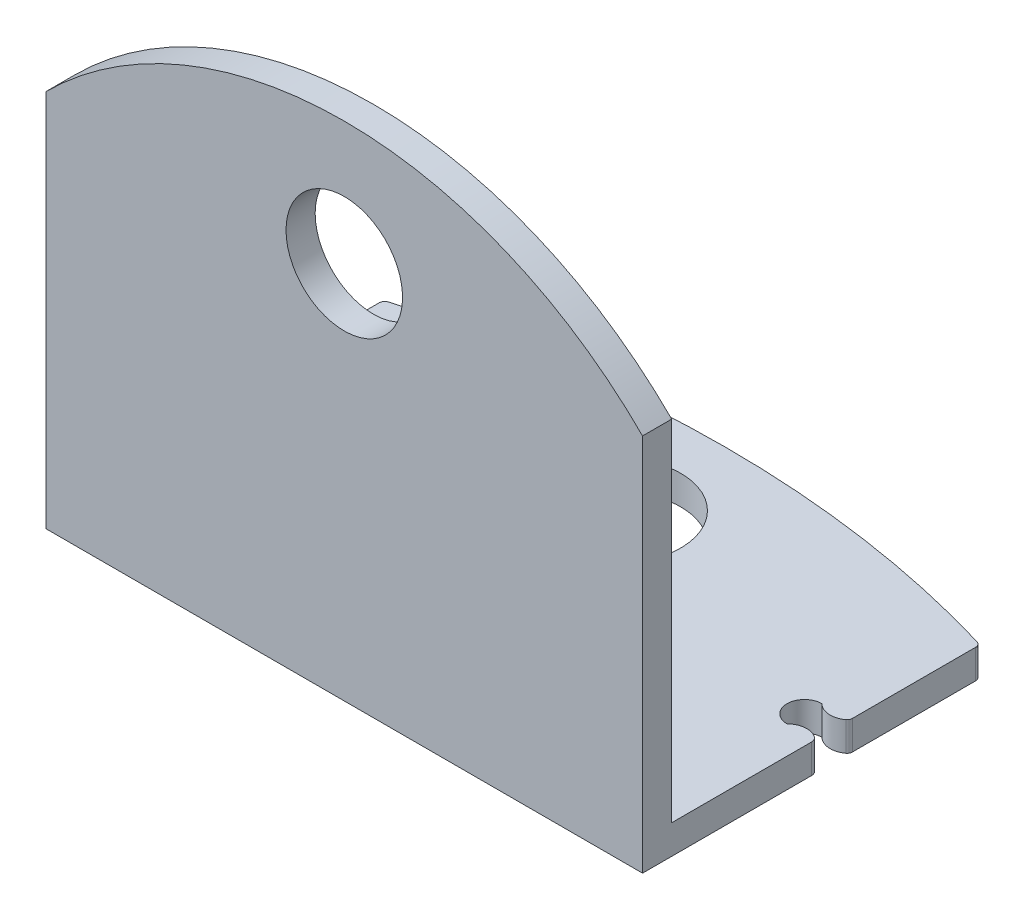
from build123d import *

# Parameters (mm, degrees)
CROQUIS1_R              = 2.228578899
SALIENTE_EXTRUIR1_DEPTH = 1
SALIENTE_EXTRUIR2_DEPTH = 1
CROQUIS4_R              = 2
CORTAR_EXTRUIR1_DEPTH   = 7


with BuildPart() as part:
    # Croquis1 → Saliente-Extruir1 (new body)
    with BuildSketch(Plane(origin=(0, 0, 0), x_dir=(1, 0, 0), z_dir=(0, 1, 0))):
        with BuildLine():
            Line((-41.112087634, 5.337620698), (-41.112087634, 1.105825587))
            ThreePointArc((-41.112087634, 1.105825587), (-41.131019498, 1.025469781), (-41.183832696, 0.962017144))
            ThreePointArc((-41.183832696, 0.962017144), (-41.639608895, 0.827195653), (-42.072087634, 1.024352746))
            ThreePointArc((-42.072087634, 1.024352746), (-42.672087634, 0.424352746), (-42.072087634, -0.175647254))
            ThreePointArc((-42.072087634, -0.175647254), (-41.6683089, 0.018882448), (-41.231302611, -0.080639282))
            ThreePointArc((-41.231302611, -0.080639282), (-41.143877149, -0.173022759), (-41.112087634, -0.296178535))
            Line((-41.112087634, -0.296178535), (-41.112087634, -5.84119357))
            ThreePointArc((-41.112087634, -5.84119357), (-41.186615392, -6.021119495), (-41.366541317, -6.095647254))
            Line((-41.366541317, -6.095647254), (-61.33763395, -6.095647254))
            ThreePointArc((-61.33763395, -6.095647254), (-61.517559875, -6.021119495), (-61.592087634, -5.84119357))
            Line((-61.592087634, -5.84119357), (-61.592087634, -0.296178535))
            ThreePointArc((-61.592087634, -0.296178535), (-61.560298119, -0.173022759), (-61.472872656, -0.080639282))
            ThreePointArc((-61.472872656, -0.080639282), (-61.035866368, 0.018882448), (-60.632087634, -0.175647254))
            ThreePointArc((-60.632087634, -0.175647254), (-60.032087634, 0.424352746), (-60.632087634, 1.024352746))
            ThreePointArc((-60.632087634, 1.024352746), (-61.064566372, 0.827195653), (-61.520342572, 0.962017144))
            ThreePointArc((-61.520342572, 0.962017144), (-61.57315577, 1.025469781), (-61.592087634, 1.105825587))
            Line((-61.592087634, 1.105825587), (-61.592087634, 5.337620698))
            ThreePointArc((-61.592087634, 5.337620698), (-61.552355908, 5.457262162), (-61.448946833, 5.529368009))
            ThreePointArc((-61.448946833, 5.529368009), (-51.352087634, 6.994851774), (-41.255228435, 5.529368009))
            ThreePointArc((-41.255228435, 5.529368009), (-41.151819359, 5.457262162), (-41.112087634, 5.337620698))
        make_face()
        with Locations((-51.352087634, 3.221723142)):
            Circle(CROQUIS1_R, mode=Mode.SUBTRACT)
    extrude(amount=SALIENTE_EXTRUIR1_DEPTH)

    # Croquis3 → Saliente-Extruir2 (add)
    with BuildSketch(Plane.XY.offset(6.095647254)):
        with BuildLine():
            Line((-61.592087634, 0), (-61.592087634, 13))
            ThreePointArc((-61.592087634, 13), (-51.352087634, 17.241546879), (-41.112087634, 13))
            Line((-41.112087634, 13), (-41.112087634, 0))
            Line((-41.112087634, 0), (-61.592087634, 0))
        make_face()
    extrude(amount=-SALIENTE_EXTRUIR2_DEPTH)

    # Croquis4 → Cortar-Extruir1 (cut)
    with BuildSketch(Plane(origin=(0, 0, 5.095647254), x_dir=(-1, 0, 0), z_dir=(0, 0, -1))):
        with Locations((51.352087634, 13)):
            Circle(CROQUIS4_R)
    extrude(amount=-CORTAR_EXTRUIR1_DEPTH, mode=Mode.SUBTRACT)


solid = part.part
